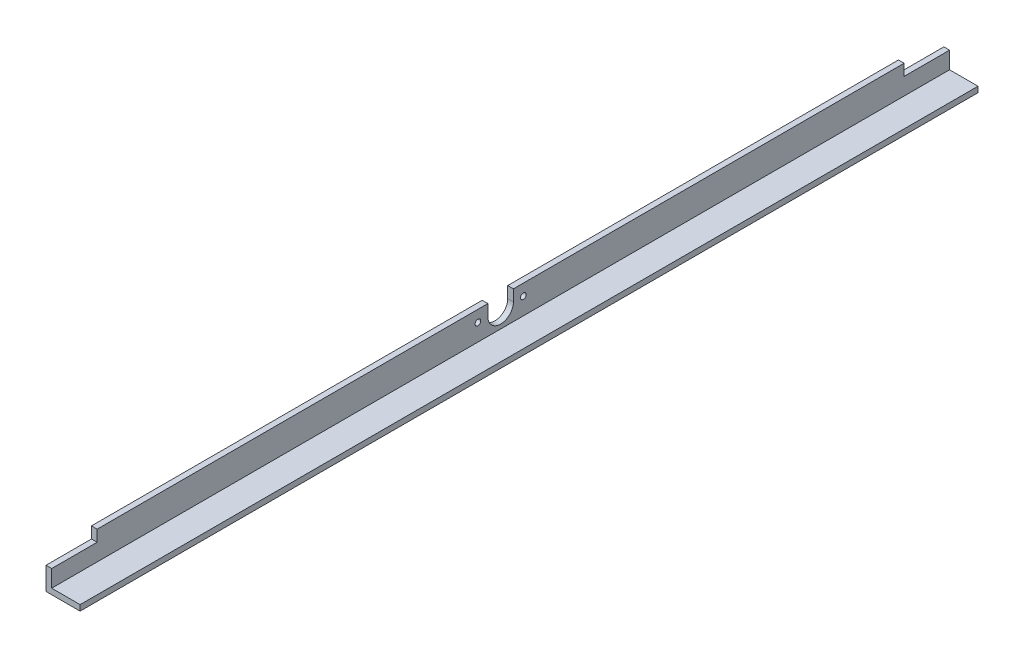
from build123d import *

# Parameters (mm, degrees)
BOSS_EXTRUDE1_DEPTH = 1003.3
CUT_EXTRUDE1_REACH  = 1006.525
SKETCH2_R           = 3.175
SKETCH3_W           = 50.8
SKETCH3_H           = 12.7
CUT_EXTRUDE2_DEPTH  = 1005.525043242


with BuildPart() as part:
    # Sketch1 → Boss-Extrude1 (new body)
    with BuildSketch(Plane.XY):
        Polygon((0, 0), (0, 38.1), (6.35, 38.1), (6.35, 6.35), (38.1, 6.35), (38.1, 0), align=None)
    extrude(amount=BOSS_EXTRUDE1_DEPTH)

    # Sketch2 → Cut-Extrude1 (cut, up to next)
    with BuildSketch(Plane(origin=(6.35, 0, 0), x_dir=(0, 0, -1), z_dir=(1, 0, 0)), mode=Mode.PRIVATE) as cut_extrude1_sk1:
        with BuildLine():
            Line((-515.9375, 38.1), (-515.9375, 25.4))
            ThreePointArc((-515.9375, 25.4), (-501.65, 11.1125), (-487.3625, 25.4))
            Line((-487.3625, 25.4), (-487.3625, 38.1))
            Line((-487.3625, 38.1), (-515.9375, 38.1))
        make_face()
    cut_extrude1_tool1 = extrude(cut_extrude1_sk1.sketch, amount=-CUT_EXTRUDE1_REACH, mode=Mode.PRIVATE) & part.part
    # Sketch2 → Cut-Extrude1 (cut, up to next)
    with BuildSketch(Plane(origin=(6.35, 0, 0), x_dir=(0, 0, -1), z_dir=(1, 0, 0)), mode=Mode.PRIVATE) as cut_extrude1_sk2:
        with Locations(Location((-527.05, 25.4, 0), (0, 0, 90))):
            Circle(SKETCH2_R)
    cut_extrude1_tool2 = extrude(cut_extrude1_sk2.sketch, amount=-CUT_EXTRUDE1_REACH, mode=Mode.PRIVATE) & part.part
    # Sketch2 → Cut-Extrude1 (cut, up to next)
    with BuildSketch(Plane(origin=(6.35, 0, 0), x_dir=(0, 0, -1), z_dir=(1, 0, 0)), mode=Mode.PRIVATE) as cut_extrude1_sk3:
        with Locations((-476.25, 25.4)):
            Circle(SKETCH2_R)
    cut_extrude1_tool3 = extrude(cut_extrude1_sk3.sketch, amount=-CUT_EXTRUDE1_REACH, mode=Mode.PRIVATE) & part.part
    add(cut_extrude1_tool1.solids().sort_by_distance((6.35, 25.926758, 501.65))[0], mode=Mode.SUBTRACT)
    add(cut_extrude1_tool2.solids().sort_by_distance((6.35, 25.4, 527.05))[0], mode=Mode.SUBTRACT)
    add(cut_extrude1_tool3.solids().sort_by_distance((6.35, 25.4, 476.25))[0], mode=Mode.SUBTRACT)

    # Sketch3 → Cut-Extrude2 (cut, through all)
    with BuildSketch(Plane(origin=(6.35, 0, 0), x_dir=(0, 0, -1), z_dir=(1, 0, 0))):
        with Locations((-25.4, 31.75)):
            Rectangle(SKETCH3_W, SKETCH3_H)
        with Locations((-977.9, 31.75)):
            Rectangle(SKETCH3_W, SKETCH3_H)
    extrude(amount=-CUT_EXTRUDE2_DEPTH, mode=Mode.SUBTRACT)


solid = part.part
